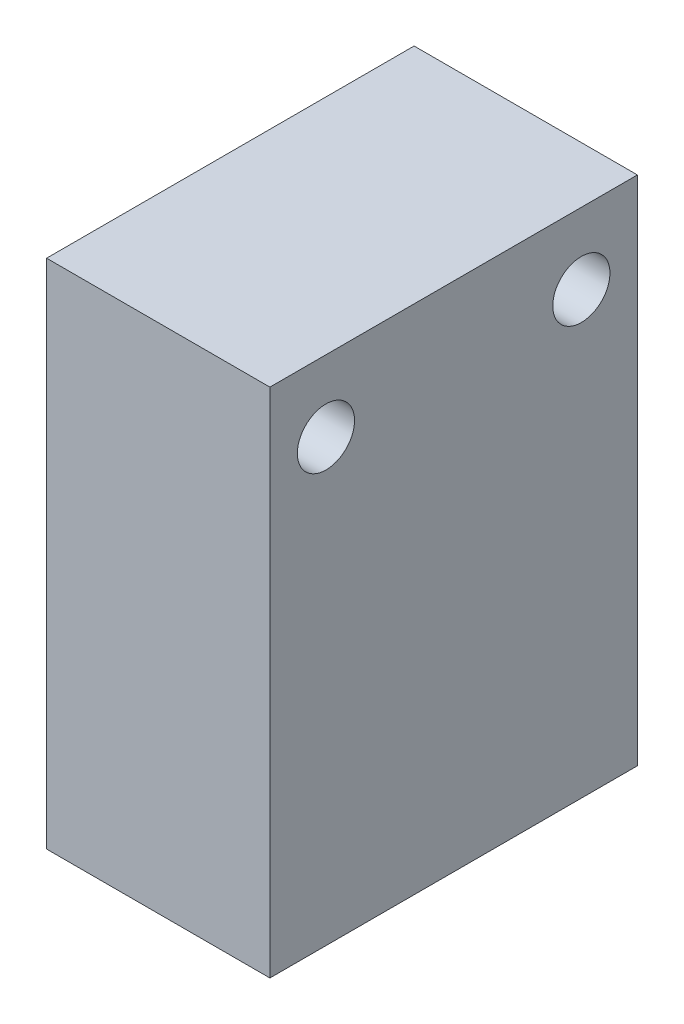
from build123d import *

# Parameters (mm, degrees)
SKETCH1_W               = 12.192
SKETCH1_H               = 20.066
BOSS_EXTRUDE1_DEPTH     = 27.94
SKETCH3_R               = 1.5621
CUT_EXTRUDE1_DEPTH      = 1
CUT_EXTRUDE1_DEPTH_BACK = 13.192


with BuildPart() as part:
    # Sketch1 → Boss-Extrude1 (new body)
    with BuildSketch(Plane(origin=(0, 0, 0), x_dir=(1, 0, 0), z_dir=(0, 1, 0))):
        Rectangle(SKETCH1_W, SKETCH1_H)
    extrude(amount=BOSS_EXTRUDE1_DEPTH)

    # Sketch3 → Cut-Extrude1 (cut, two sides)
    with BuildSketch(Plane.ZY.offset(6.096)) as cut_extrude1_sk:
        with Locations((-6.9723, 24.0538)):
            Circle(SKETCH3_R)
        with Locations((6.9723, 24.0538)):
            Circle(SKETCH3_R)
    extrude(amount=CUT_EXTRUDE1_DEPTH, mode=Mode.SUBTRACT)
    extrude(cut_extrude1_sk.sketch, amount=-CUT_EXTRUDE1_DEPTH_BACK, mode=Mode.SUBTRACT)


solid = part.part
